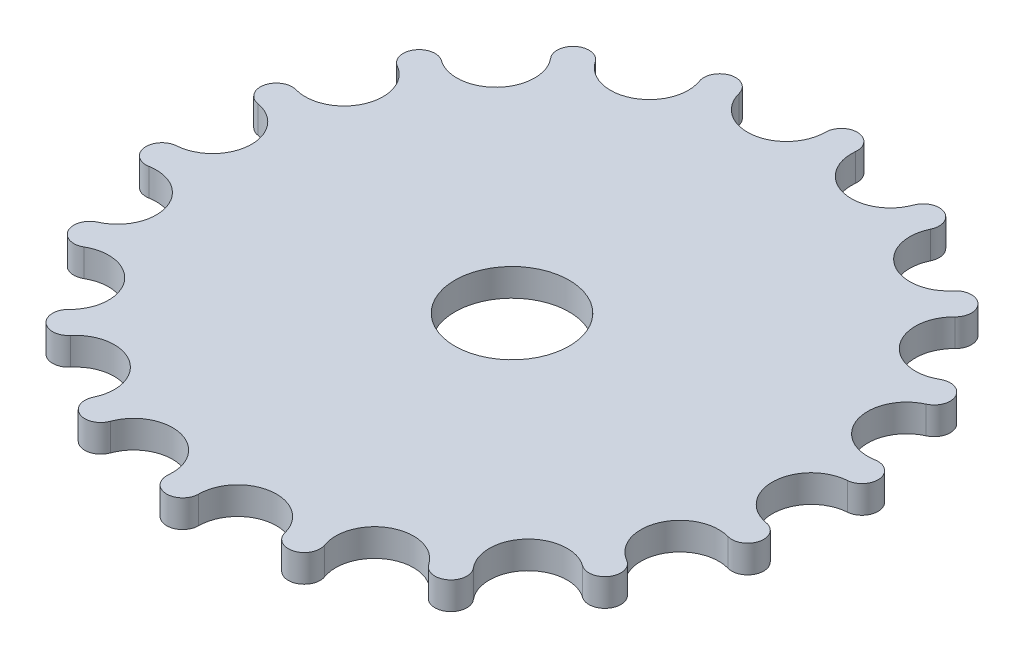
from build123d import *

# Parameters (mm, degrees)
SKETCH1_R           = 6.604
BOSS_EXTRUDE1_DEPTH = 3.175


with BuildPart() as part:
    # Sketch1 → Boss-Extrude1 (new body)
    with BuildSketch(Plane(origin=(0, 0, 0), x_dir=(1, 0, 0), z_dir=(0, 1, 0))):
        with BuildLine():
            ThreePointArc((0, -36.208877371), (3.945014404, -31.74323173), (8.863107106, -35.107380035))
            ThreePointArc((8.863107106, -35.107380035), (11.19297859, -36.418775793), (12.384165428, -34.025214873))
            ThreePointArc((12.384165428, -34.025214873), (14.563925591, -28.479606225), (20.336027496, -29.958784791))
            ThreePointArc((20.336027496, -29.958784791), (22.973914302, -30.39423073), (23.274617735, -27.737609302))
            ThreePointArc((23.274617735, -27.737609302), (23.42621241, -21.780919895), (29.356122842, -21.196717957))
            ThreePointArc((29.356122842, -21.196717957), (31.98385689, -20.703692869), (31.357807646, -18.104438686))
            ThreePointArc((31.357807646, -18.104438686), (29.462952279, -12.455133173), (34.835436523, -9.878014107))
            ThreePointArc((34.835436523, -9.878014107), (37.136074307, -8.515984094), (35.658783163, -6.287605571))
            ThreePointArc((35.658783163, -6.287605571), (31.946025276, -1.627073572), (36.113082444, 2.632124028))
            ThreePointArc((36.113082444, 2.632124028), (37.809133091, 4.698878045), (35.658783163, 6.287605571))
            ThreePointArc((35.658783163, 6.287605571), (30.575936152, 9.397235114), (33.034957649, 14.824789159))
            ThreePointArc((33.034957649, 14.824789159), (33.921852422, 17.346986144), (31.357807646, 18.104438686))
            ThreePointArc((31.357807646, 18.104438686), (25.517937875, 19.288098557), (25.972329417, 25.229365928))
            ThreePointArc((25.972329417, 25.229365928), (25.943095717, 27.902791699), (23.274617735, 27.737609302))
            ThreePointArc((23.274617735, 27.737609302), (17.382099685, 26.852532653), (15.777054948, 32.590908819))
            ThreePointArc((15.777054948, 32.590908819), (14.835218789, 35.093108775), (12.384165428, 34.025214873))
            ThreePointArc((12.384165428, 34.025214873), (7.149723742, 31.178155009), (3.678834807, 36.021507116))
            ThreePointArc((3.678834807, 36.021507116), (1.937995531, 38.050679013), (0, 36.208877371))
            ThreePointArc((0, 36.208877371), (-3.945014404, 31.74323173), (-8.863107106, 35.107380035))
            ThreePointArc((-8.863107106, 35.107380035), (-11.19297859, 36.418775793), (-12.384165428, 34.025214873))
            ThreePointArc((-12.384165428, 34.025214873), (-14.563925591, 28.479606225), (-20.336027496, 29.958784791))
            ThreePointArc((-20.336027496, 29.958784791), (-22.973914302, 30.39423073), (-23.274617735, 27.737609302))
            ThreePointArc((-23.274617735, 27.737609302), (-23.42621241, 21.780919895), (-29.356122842, 21.196717957))
            ThreePointArc((-29.356122842, 21.196717957), (-31.98385689, 20.703692869), (-31.357807646, 18.104438686))
            ThreePointArc((-31.357807646, 18.104438686), (-29.462952279, 12.455133173), (-34.835436523, 9.878014107))
            ThreePointArc((-34.835436523, 9.878014107), (-37.136074307, 8.515984094), (-35.658783163, 6.287605571))
            ThreePointArc((-35.658783163, 6.287605571), (-31.946025276, 1.627073572), (-36.113082444, -2.632124028))
            ThreePointArc((-36.113082444, -2.632124028), (-37.809133091, -4.698878045), (-35.658783163, -6.287605571))
            ThreePointArc((-35.658783163, -6.287605571), (-30.575936152, -9.397235114), (-33.034957649, -14.824789159))
            ThreePointArc((-33.034957649, -14.824789159), (-33.921852422, -17.346986144), (-31.357807646, -18.104438686))
            ThreePointArc((-31.357807646, -18.104438686), (-25.517937875, -19.288098557), (-25.972329417, -25.229365928))
            ThreePointArc((-25.972329417, -25.229365928), (-25.943095717, -27.902791699), (-23.274617735, -27.737609302))
            ThreePointArc((-23.274617735, -27.737609302), (-17.382099685, -26.852532653), (-15.777054948, -32.590908819))
            ThreePointArc((-15.777054948, -32.590908819), (-14.835218789, -35.093108775), (-12.384165428, -34.025214873))
            ThreePointArc((-12.384165428, -34.025214873), (-7.149723742, -31.178155009), (-3.678834807, -36.021507116))
            ThreePointArc((-3.678834807, -36.021507116), (-1.937995531, -38.050679013), (0, -36.208877371))
        make_face()
        with Locations(Location((0, 0, 0), (0, 0, 270))):  # turned: the seam where the file's is
            Circle(SKETCH1_R, mode=Mode.SUBTRACT)
    extrude(amount=BOSS_EXTRUDE1_DEPTH)


solid = part.part
